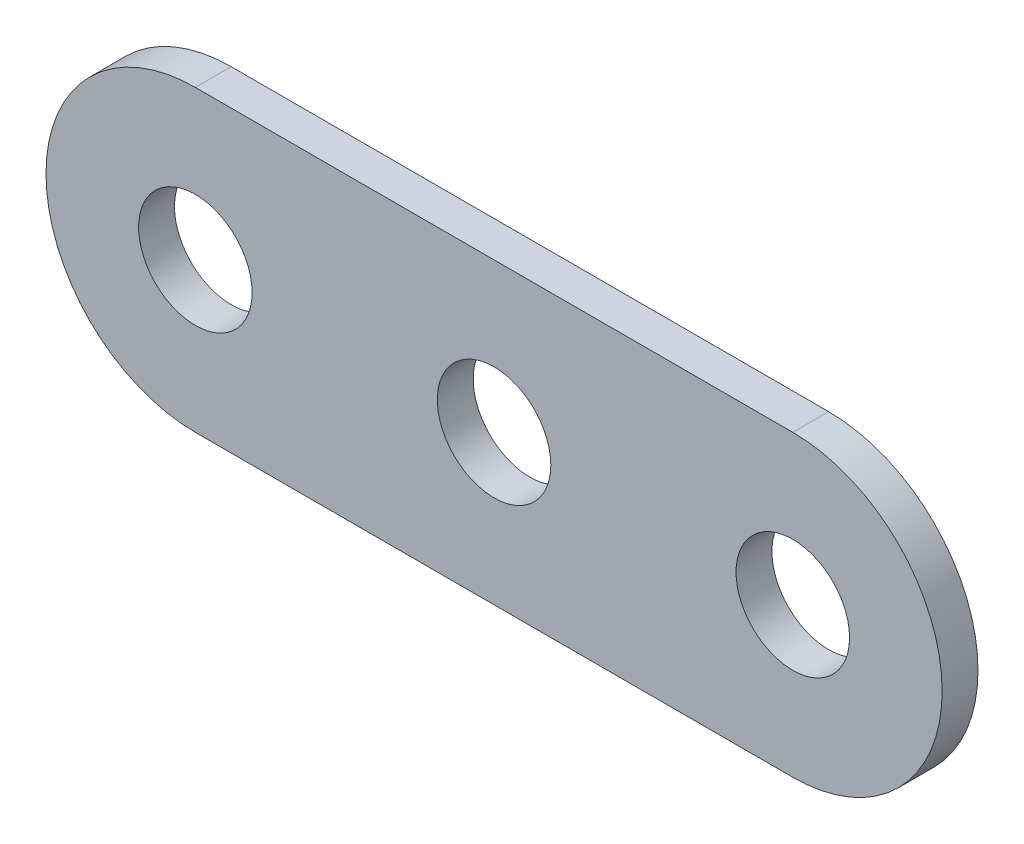
from build123d import *

# Parameters (mm, degrees)
EXTRUDE1_DEPTH  = 1.524
SKETCH2_R       = 2.413
EXTRUDE2_DEPTH  = 2.524
LPATTERN1_COUNT = 3
LPATTERN1_PITCH = 12.7


with BuildPart() as part:
    # Sketch1 → Extrude1 (new body)
    with BuildSketch(Plane.XY):
        with BuildLine():
            Line((-12.7, -6.35), (12.7, -6.35))
            ThreePointArc((12.7, -6.35), (19.05, 0), (12.7, 6.35))
            Line((12.7, 6.35), (-12.7, 6.35))
            ThreePointArc((-12.7, 6.35), (-19.05, 0), (-12.7, -6.35))
        make_face()
    extrude(amount=EXTRUDE1_DEPTH)

    # Sketch2 → Extrude2 (cut, through all)
    with BuildSketch(Plane.XY.offset(1.524)):
        with Locations((-12.7, 0)):
            Circle(SKETCH2_R)
    extrude2 = extrude(amount=-EXTRUDE2_DEPTH, mode=Mode.SUBTRACT)

    # LPattern1: Extrude2 ×3
    with Locations(*[(i * LPATTERN1_PITCH, 0, 0) for i in range(1, LPATTERN1_COUNT)]):
        add(extrude2, mode=Mode.SUBTRACT)


solid = part.part
